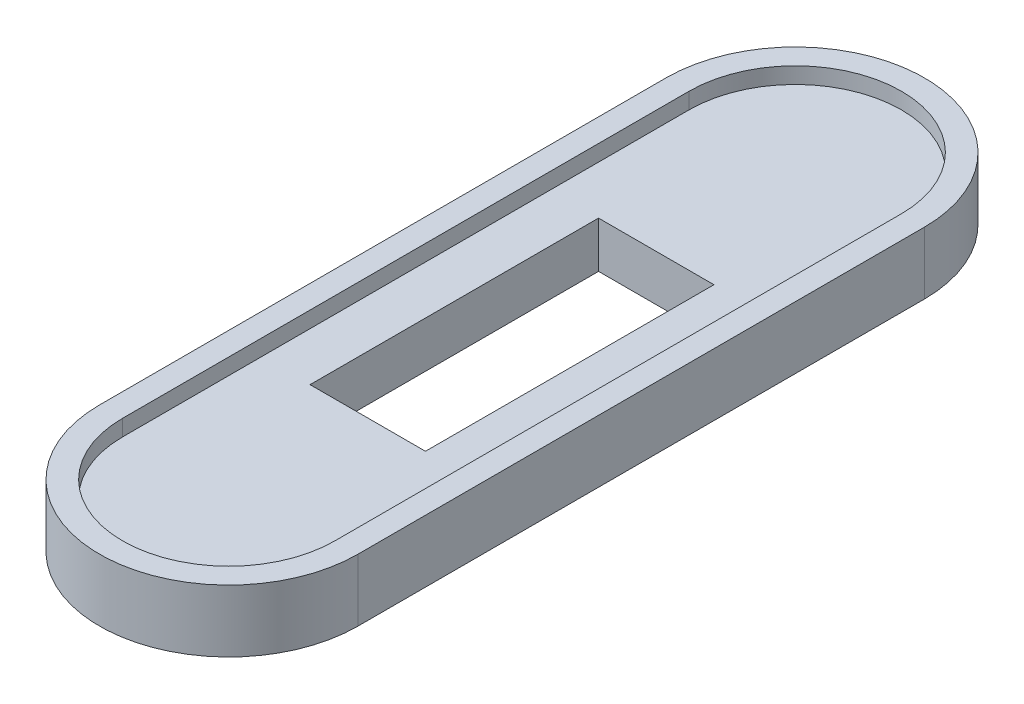
from build123d import *

# Parameters (mm, degrees)
EXTRUDE_THIN1_DEPTH = 1.4
SKETCH2_W           = 10
SKETCH2_H           = 25
BOSS_EXTRUDE1_DEPTH = 4


with BuildPart() as part:
    # Sketch1 → Extrude-Thin1 (new body)
    with BuildSketch(Plane(origin=(0, 0, 0), x_dir=(1, 0, 0), z_dir=(0, 1, 0))):
        with BuildLine():
            Line((-2, 0), (-2, 49.1))
            ThreePointArc((-2, 49.1), (9.2, 60.3), (20.4, 49.1))
            Line((20.4, 49.1), (20.4, 0))
            ThreePointArc((20.4, 0), (9.2, -11.2), (-2, 0))
        make_face()
        with BuildLine():
            Line((0, 0), (0, 49.1))
            ThreePointArc((0, 49.1), (9.2, 58.3), (18.4, 49.1))
            Line((18.4, 49.1), (18.4, 0))
            ThreePointArc((18.4, 0), (9.2, -9.2), (0, 0))
        make_face(mode=Mode.SUBTRACT)
    extrude(amount=EXTRUDE_THIN1_DEPTH)

    # Sketch2 → Boss-Extrude1 (add)
    with BuildSketch(Plane.XZ):
        with BuildLine():
            Line((-2, 0), (-2, -49.1))
            ThreePointArc((-2, -49.1), (9.2, -60.3), (20.4, -49.1))
            Line((20.4, -49.1), (20.4, 0))
            ThreePointArc((20.4, 0), (9.2, 11.2), (-2, 0))
        make_face()
        with Locations((9.2, -24.55)):
            Rectangle(SKETCH2_W, SKETCH2_H, mode=Mode.SUBTRACT)
    extrude(amount=BOSS_EXTRUDE1_DEPTH)


solid = part.part
